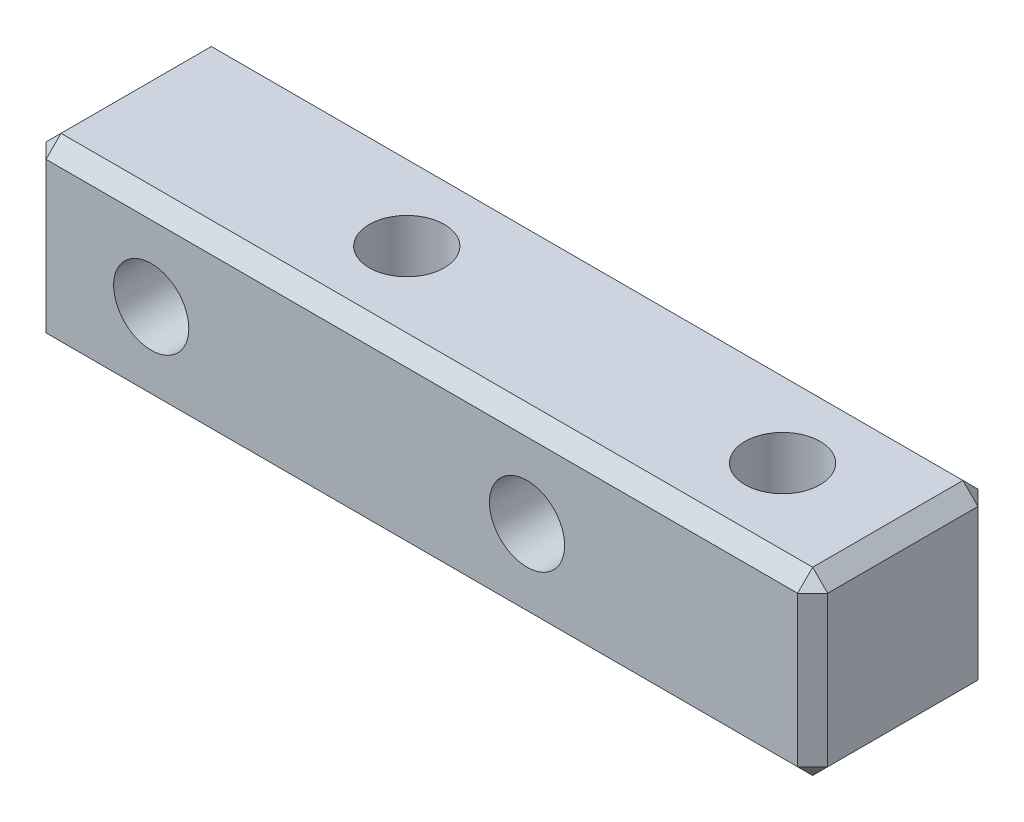
from build123d import *

# Parameters (mm, degrees)
SKETCH_1_W         = 26
SKETCH_1_H         = 6
EXTRUDE_1_DEPTH    = 6
CHAMFER_1_SIZE     = 0.5
HOLE_WIZARD_M3_1_D = 2.5
HOLE_WIZARD_M3_2_D = 2.5


with BuildPart() as part:
    # 草图1 → 凸台-拉伸1 (new body)
    with BuildSketch(Plane.XY):
        Rectangle(SKETCH_1_W, SKETCH_1_H)
    extrude(amount=EXTRUDE_1_DEPTH)

    # 倒角1
    chamfer_1_edges = [part.edges().sort_by_distance(p)[0] for p in [
        (-13, 0, 6),
        (0, -3, 6),
        (13, 0, 6),
        (0, -3, 0),
        (-13, 0, 0),
        (0, 3, 0),
        (13, 0, 0),
        (13, -3, 3),
        (-13, -3, 3),
        (-13, 3, 3),
        (13, 3, 3),
        (0, 3, 6),
    ]]
    chamfer(chamfer_1_edges, length=CHAMFER_1_SIZE)

    # M3 螺纹孔1 (through all)
    with Locations(Plane(origin=(-9, 0, 6), x_dir=(1, 0, 0), z_dir=(0, 0, 1))):
        with Locations((0, 0), (12.5, 0)):
            Hole(HOLE_WIZARD_M3_1_D / 2)

    # M3 螺纹孔2 (through all)
    with Locations(Plane(origin=(-3.5, 3, 3), x_dir=(0, 0, 1), z_dir=(0, 1, 0))):
        with Locations((0, 0), (0, 12.5)):
            Hole(HOLE_WIZARD_M3_2_D / 2)


solid = part.part
